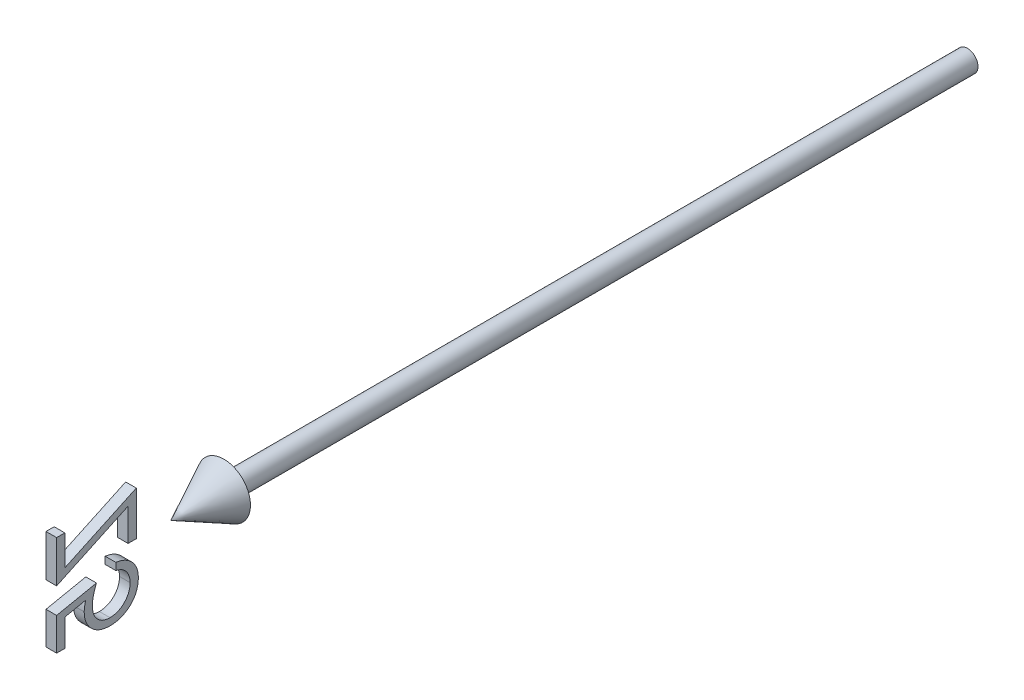
from build123d import *

# Parameters (mm, degrees)
BOSS_EXTRUDE1_DEPTH        = 1
BOSS_EXTRUDE1_DEPTH_BACK   = 1
BOSS_EXTRUDE1_2_DEPTH      = 1
BOSS_EXTRUDE1_2_DEPTH_BACK = 1


with BuildPart() as part:
    # Sketch2 → Revolve1 (revolve)
    with BuildSketch(Plane(origin=(0, 0, 0), x_dir=(1, 0, 0), z_dir=(0, 1, 0))):
        Polygon((0, -150), (5, -140), (2, -140), (2, 0), (0, 0), align=None)
    revolve(axis=Axis((0, 0, -41.949952025), (0, 0, 1)))


with BuildPart() as body_2:
    # Sketch3 → Boss-Extrude1 (new, two sides: drawn at the far end of the back side and taken through both)
    with BuildSketch(Plane(origin=(0, 0, 0), x_dir=(0, -1, 0), z_dir=(1, 0, 0)).offset(-BOSS_EXTRUDE1_DEPTH_BACK)):
        Polygon((-8.958586521, -170.961538462), (-8.958586521, -172.5), (-1.073971137, -172.5), (-7.366038444, -159.038461538), (-1.266278829, -159.038461538), (-1.266278829, -157.5), (-9.535509598, -157.5), (-3.243442291, -170.961538462), align=None)
    extrude(amount=BOSS_EXTRUDE1_DEPTH + BOSS_EXTRUDE1_DEPTH_BACK)


with BuildPart() as body_3:
    # Sketch3 → Boss-Extrude1 2 (new, two sides: drawn at the far end of the back side and taken through both)
    with BuildSketch(Plane(origin=(0, 0, 0), x_dir=(0, -1, 0), z_dir=(1, 0, 0)).offset(-BOSS_EXTRUDE1_2_DEPTH_BACK)):
        with BuildLine():
            Line((9.887567325, -172.5), (9.887567325, -170.961538462))
            Line((9.887567325, -170.961538462), (4.785403863, -170.961538462))
            Line((4.785403863, -170.961538462), (3.977110594, -167.016225962))
            add(Edge.make_bspline(
                [(3.977110594, -167.016225962), (4.135921484, -167.060069984), (4.443592466, -167.145010842), (4.897706156, -167.239321287), (5.3288156, -167.29617319), (5.608567187, -167.303935949), (5.743937517, -167.307692308)],
                knots=[0, 0, 0, 0, 1.100273476, 2.13160584, 3.095893838, 4, 4, 4, 4], degree=3))
            add(Edge.make_bspline(
                [(5.743937517, -167.307692308), (5.911469427, -167.304185649), (6.24087902, -167.297290681), (6.722105689, -167.227184909), (7.183764435, -167.125573837), (7.619214914, -166.969276616), (8.035477483, -166.777179721), (8.426908648, -166.538369816), (8.795347102, -166.256249819), (9.139987498, -165.936607073), (9.450692918, -165.58071989), (9.721766713, -165.197753494), (9.953469806, -164.791981219), (10.13830025, -164.359670651), (10.288157328, -163.904895851), (10.387242998, -163.423840767), (10.453352538, -162.920507804), (10.460728922, -162.57634312), (10.464490402, -162.400841346)],
                knots=[0, 0, 0, 0, 1.052656913, 2.069786496, 3.052102726, 4.020122636, 4.972424848, 5.930457368, 6.896570172, 7.885826804, 8.881139003, 9.861434336, 10.831623367, 11.813212553, 12.812997731, 13.836986694, 14.897002833, 16, 16, 16, 16], degree=3))
            add(Edge.make_bspline(
                [(10.464490402, -162.400841346), (10.461637896, -162.278603862), (10.455971432, -162.035780828), (10.4272095, -161.675153979), (10.371651619, -161.322203317), (10.297859754, -160.977627952), (10.199737382, -160.640913658), (10.083702808, -160.311265984), (9.94481725, -159.989230296), (9.78632982, -159.676409009), (9.606012689, -159.378959247), (9.41357379, -159.093415078), (9.203882177, -158.828060432), (8.980608649, -158.578459857), (8.739466144, -158.351792308), (8.486372312, -158.13860225), (8.215667474, -157.947932487), (7.932123942, -157.772571018), (7.635940617, -157.615556084), (7.324108821, -157.484578375), (7.003475543, -157.36977506), (6.671182611, -157.276416452), (6.327873889, -157.203983651), (5.972367137, -157.1546579), (5.606446231, -157.118769123), (5.358410975, -157.116520479), (5.233120209, -157.115384615)],
                knots=[0, 0, 0, 0, 1.056281413, 2.098288097, 3.122646807, 4.141030392, 5.140675379, 6.150604744, 7.15845591, 8.168533554, 9.177684096, 10.161739049, 11.141561652, 12.097360316, 13.052218386, 13.998410789, 14.954052752, 15.909851415, 16.877523809, 17.846742625, 18.829312613, 19.818263486, 20.826374662, 21.858017533, 22.918014209, 24, 24, 24, 24], degree=3))
            add(Edge.make_bspline(
                [(5.233120209, -157.115384615), (5.083663432, -157.118353573), (4.789624879, -157.124194647), (4.358765469, -157.185013786), (3.944482382, -157.272715803), (3.548493848, -157.402581355), (3.17266208, -157.572879113), (2.811535272, -157.773917029), (2.471723833, -158.016561831), (2.150816973, -158.292114808), (1.856439093, -158.597737608), (1.585431088, -158.922660627), (1.350772111, -159.274090548), (1.146876605, -159.646164401), (0.973427436, -160.03985218), (0.837046103, -160.456067664), (0.72700461, -160.892789077), (0.680445908, -161.193445999), (0.656798094, -161.346153846)],
                knots=[0, 0, 0, 0, 1.04695683, 2.059763882, 3.044413726, 4.012427942, 4.974081556, 5.932886124, 6.904940154, 7.895678616, 8.893654631, 9.876199664, 10.857615262, 11.850515636, 12.847107701, 13.868396357, 14.917328757, 16, 16, 16, 16], degree=3))
            Line((0.656798094, -161.346153846), (2.00295194, -161.346153846))
            add(Edge.make_bspline(
                [(2.00295194, -161.346153846), (2.036032743, -161.203083199), (2.099615882, -160.928093472), (2.23990822, -160.542198326), (2.408726247, -160.196889026), (2.618776332, -159.894337129), (2.857370729, -159.624358707), (3.132747288, -159.384274178), (3.442565873, -159.170288137), (3.786895688, -158.990462771), (4.151090117, -158.839207909), (4.530034101, -158.731213569), (4.918346783, -158.665854967), (5.179786156, -158.657864157), (5.311245209, -158.653846154)],
                knots=[0, 0, 0, 0, 1.136370375, 2.184166959, 3.172867797, 4.104539607, 5.027679118, 5.956634301, 6.927059835, 7.936867459, 8.959641981, 9.976160943, 10.98235693, 12, 12, 12, 12], degree=3))
            add(Edge.make_bspline(
                [(5.311245209, -158.653846154), (5.439627651, -158.657393206), (5.692413729, -158.66437738), (6.064618753, -158.717265273), (6.422918413, -158.800858252), (6.767948739, -158.917967227), (7.098014319, -159.072895535), (7.412648474, -159.263216032), (7.716333445, -159.484180393), (8.0010767, -159.736734594), (8.26180345, -160.01520754), (8.49219042, -160.312959591), (8.684090536, -160.630605369), (8.845808395, -160.962632597), (8.96860818, -161.31268371), (9.056212403, -161.679117276), (9.107654079, -162.062838631), (9.114730565, -162.324564243), (9.118336556, -162.457932692)],
                knots=[0, 0, 0, 0, 1.027268864, 2.022700798, 3.002744649, 3.968653148, 4.933396556, 5.915045722, 6.907600446, 7.935526002, 8.956456544, 9.95700807, 10.942805781, 11.92166854, 12.907987664, 13.905483474, 14.932689774, 16, 16, 16, 16], degree=3))
            add(Edge.make_bspline(
                [(9.118336556, -162.457932692), (9.11605731, -162.578344541), (9.111612247, -162.813175926), (9.059043658, -163.156423063), (8.98823791, -163.484071376), (8.876564493, -163.793059521), (8.740921344, -164.086613326), (8.564183938, -164.357479425), (8.36878926, -164.618902079), (8.134790794, -164.853598193), (7.88142437, -165.072021918), (7.600648632, -165.257275951), (7.300487573, -165.414892638), (6.980241671, -165.54401236), (6.639555436, -165.646871335), (6.27823456, -165.71795725), (5.896199729, -165.760494324), (5.634875518, -165.766264664), (5.500548094, -165.769230769)],
                knots=[0, 0, 0, 0, 1.045820996, 2.039596555, 3.013371638, 3.9552447, 4.890047302, 5.817684688, 6.761648481, 7.722253242, 8.692244539, 9.66551337, 10.63924952, 11.635311376, 12.662847378, 13.728455105, 14.832366986, 16, 16, 16, 16], degree=3))
            add(Edge.make_bspline(
                [(5.500548094, -165.769230769), (5.383271567, -165.766827016), (5.14318831, -165.76190616), (4.774060713, -165.723180046), (4.387850998, -165.663603645), (3.983059776, -165.57773504), (3.560797928, -165.470221633), (3.120363225, -165.335950868), (2.661745026, -165.18128788), (2.353062139, -165.061325997), (2.195259633, -165)],
                knots=[0, 0, 0, 0, 0.824638674, 1.688163388, 2.607705698, 3.571998603, 4.597075385, 5.671199175, 6.809488238, 8, 8, 8, 8], degree=3))
            Line((2.195259633, -165), (3.733721171, -172.5))
            Line((3.733721171, -172.5), (9.887567325, -172.5))
        make_face()
    extrude(amount=BOSS_EXTRUDE1_2_DEPTH + BOSS_EXTRUDE1_2_DEPTH_BACK)


solid = Compound([part.part, body_2.part, body_3.part])
